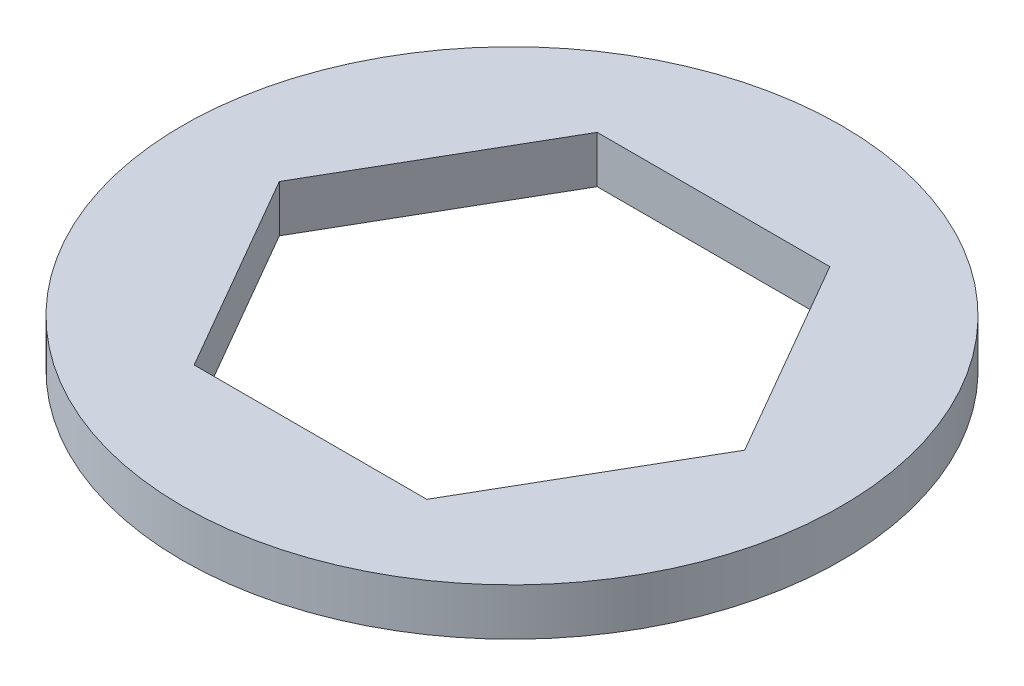
from build123d import *

# Parameters (mm, degrees)
SKETCH1_R           = 11.1125
BOSS_EXTRUDE1_DEPTH = 1.5875


with BuildPart() as part:
    # Sketch1 → Boss-Extrude1 (new body)
    with BuildSketch(Plane(origin=(0, 0, 0), x_dir=(1, 0, 0), z_dir=(0, 1, 0))):
        Circle(SKETCH1_R)
        Polygon((7.845612808, 0), (3.922806404, 6.7945), (-3.922806404, 6.7945), (-7.845612808, 0), (-3.922806404, -6.7945), (3.922806404, -6.7945), align=None, mode=Mode.SUBTRACT)
    extrude(amount=BOSS_EXTRUDE1_DEPTH)


solid = part.part
